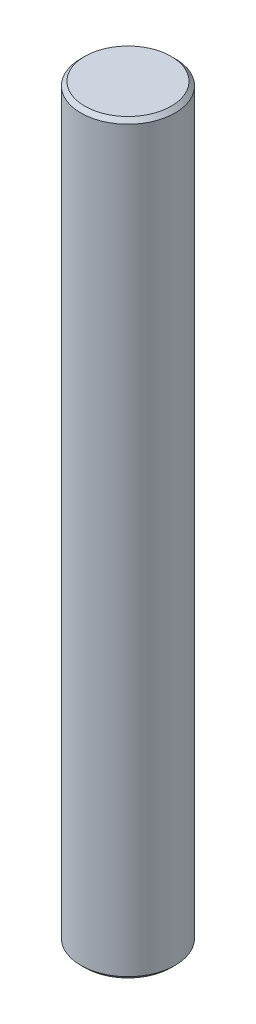
from build123d import *

# Parameters (mm, degrees)
SKETCH1_R           = 6
BOSS_EXTRUDE1_DEPTH = 95
CHAMFER1_SIZE       = 0.5


with BuildPart() as part:
    # Sketch1 → Boss-Extrude1 (new body)
    with BuildSketch(Plane(origin=(0, 0, 0), x_dir=(1, 0, 0), z_dir=(0, 1, 0))):
        Circle(SKETCH1_R)
    extrude(amount=BOSS_EXTRUDE1_DEPTH)

    # Chamfer1
    chamfer1_edges = [part.edges().sort_by_distance(p)[0] for p in [
        (-6, 0, 0),
        (-6, 95, 0),
    ]]
    chamfer(chamfer1_edges, length=CHAMFER1_SIZE)


solid = part.part
